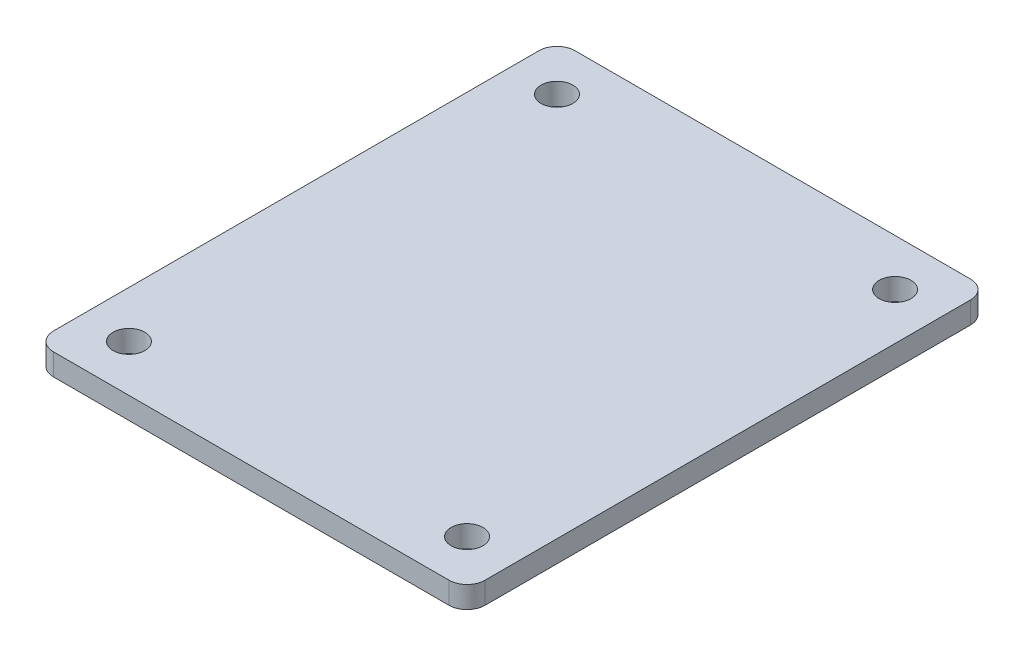
from build123d import *

# Parameters (mm, degrees)
SKETCH1_W             = 60.96
SKETCH1_H             = 73.66
BOSS_EXTRUDE1_DEPTH   = 3.0734
FILLET1_R             = 2.54
F_8_CLEARANCE_HOLE1_D = 4.4958


with BuildPart() as part:
    # Sketch1 → Boss-Extrude1 (new body)
    with BuildSketch(Plane(origin=(0, 0, 0), x_dir=(1, 0, 0), z_dir=(0, 1, 0))):
        with Locations((30.48, 36.83)):
            Rectangle(SKETCH1_W, SKETCH1_H)
    extrude(amount=BOSS_EXTRUDE1_DEPTH)

    # Fillet1
    fillet1_edges = [part.edges().sort_by_distance(p)[0] for p in [
        (0, 1.5367, -73.66),
        (60.96, 1.5367, -73.66),
        (60.96, 1.5367, 0),
        (0, 1.5367, 0),
    ]]
    fillet(fillet1_edges, radius=FILLET1_R)

    # #8 Clearance Hole1 (through all)
    with Locations(Plane(origin=(0, 3.0734, 0), x_dir=(1, 0, 0), z_dir=(0, 1, 0))):
        with Locations((54.356, 67.056), (54.356, 6.604), (6.604, 67.056), (6.604, 6.604)):
            Hole(F_8_CLEARANCE_HOLE1_D / 2)


solid = part.part
